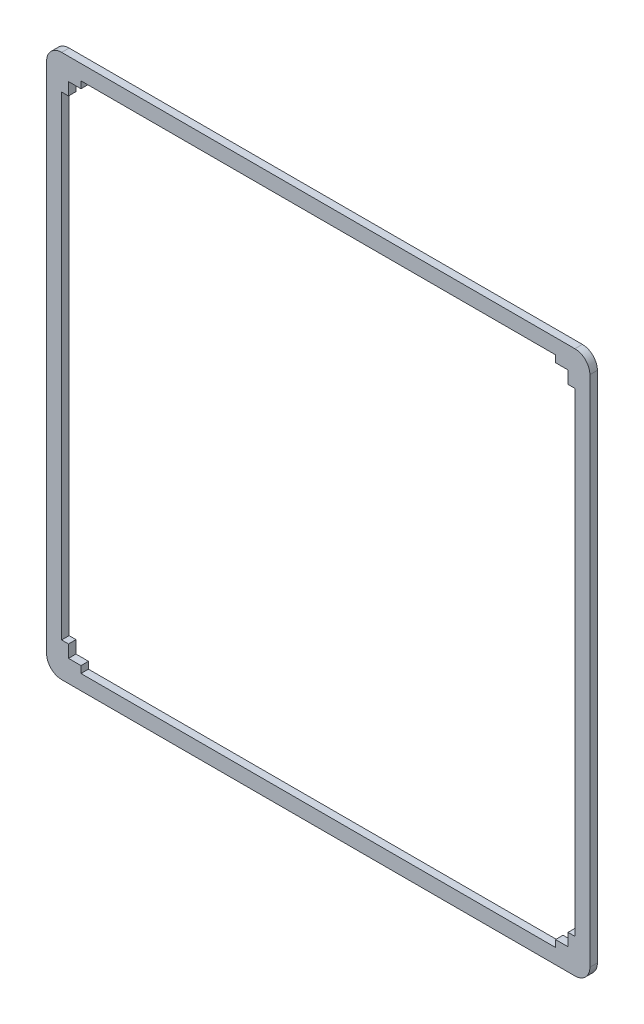
from build123d import *

# Parameters (mm, degrees)
EXTRUDE_1_DEPTH = 3


with BuildPart() as part:
    # 草图1 → 凸台-拉伸1 (new body)
    with BuildSketch(Plane.XY):
        with BuildLine():
            Line((-8.75, 202.75), (-8.75, -2.75))
            ThreePointArc((-8.75, -2.75), (-6.992640687, -6.992640687), (-2.75, -8.75))
            Line((-2.75, -8.75), (202.75, -8.75))
            ThreePointArc((202.75, -8.75), (206.992640687, -6.992640687), (208.75, -2.75))
            Line((208.75, -2.75), (208.75, 202.75))
            ThreePointArc((208.75, 202.75), (206.992640687, 206.992640687), (202.75, 208.75))
            Line((202.75, 208.75), (-2.75, 208.75))
            ThreePointArc((-2.75, 208.75), (-6.992640687, 206.992640687), (-8.75, 202.75))
        make_face()
        Polygon((5, 202.75), (5, 200), (0, 200), (0, 195), (-2.75, 195), (-2.75, 5), (0, 5), (0, 0), (5, 0), (5, -2.75), (195, -2.75), (195, 0), (200, 0), (200, 5), (202.75, 5), (202.75, 195), (200, 195), (200, 200), (195, 200), (195, 202.75), align=None, mode=Mode.SUBTRACT)
    extrude(amount=EXTRUDE_1_DEPTH)


solid = part.part
